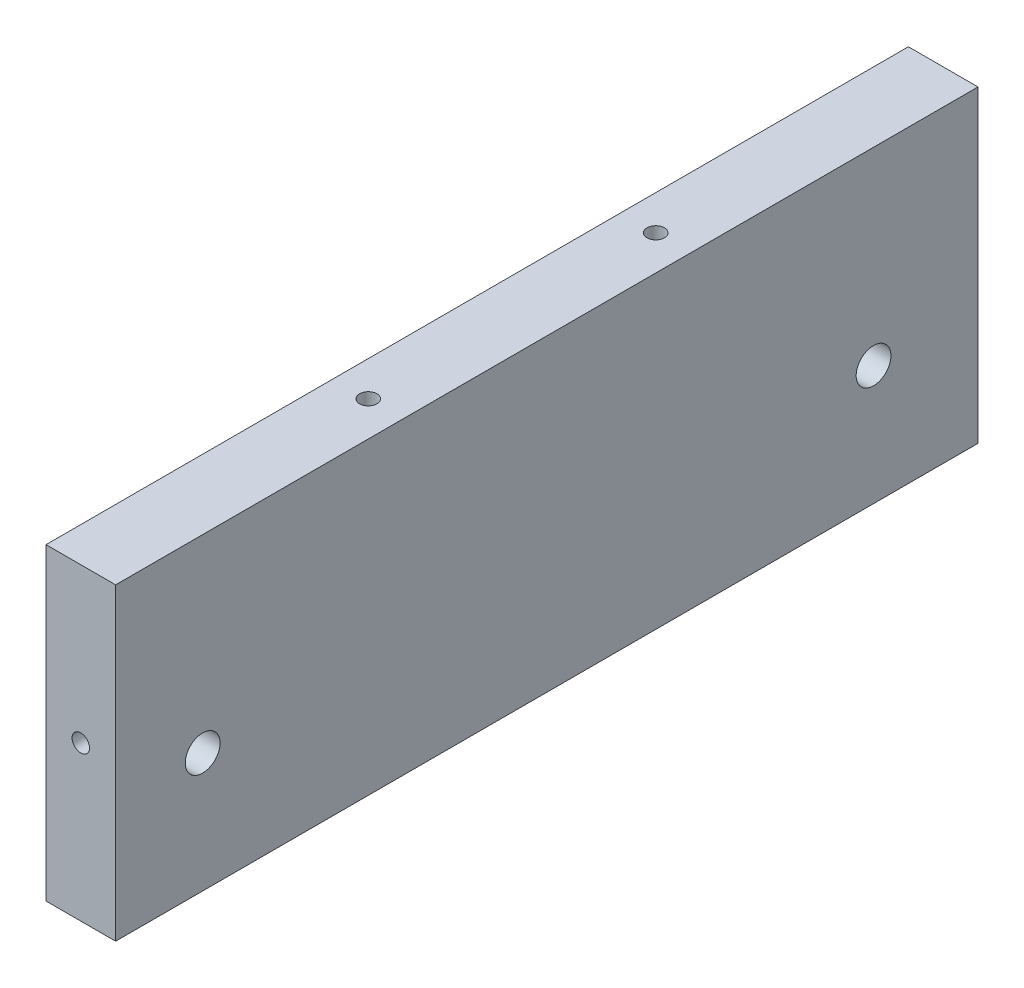
from build123d import *

# Parameters (mm, degrees)
SKETCH1_W                   = 12.7
SKETCH1_H                   = 56.3
BOSS_EXTRUDE1_DEPTH         = 157.3
HOLE1_D                     = 3.175
HOLE1_DEPTH                 = 31.75
HOLE1_CSINK_D               = 10.16
HOLE1_CSINK_ANGLE           = 82
HOLE1_TIP                   = 0.953866233
HOLE2_D                     = 3.175
HOLE2_DEPTH                 = 31.75
HOLE2_CSINK_D               = 10.16
HOLE2_CSINK_ANGLE           = 82
HOLE2_TIP                   = 0.953866233
HOLE_D                      = 3.175
HOLE_DEPTH                  = 31.75
HOLE_CSINK_D                = 10.16
HOLE_CSINK_ANGLE            = 82
HOLE_TIP                    = 0.953866233
HOLE3_D                     = 3.175
HOLE3_DEPTH                 = 31.75
HOLE3_CSINK_D               = 10.16
HOLE3_CSINK_ANGLE           = 82
HOLE3_TIP                   = 0.953866233
HOLE4_D                     = 3.175
HOLE4_DEPTH                 = 31.75
HOLE4_CSINK_D               = 10.16
HOLE4_CSINK_ANGLE           = 82
HOLE4_TIP                   = 0.953866233
F_1_4_0_25_DIAMETER_HOLE1_D = 6.35


with BuildPart() as part:
    # Sketch1 → Boss-Extrude1 (new body)
    with BuildSketch(Plane.XY):
        with Locations((-237.654465963, 40.85)):
            Rectangle(SKETCH1_W, SKETCH1_H)
    extrude(amount=BOSS_EXTRUDE1_DEPTH)

    # Hole1
    with Locations(Plane(origin=(-124.004465969, 0, 2.275709941), x_dir=(1, 0, 0), z_dir=(0, -1, 0))):
        with Locations((113.649999994, 128.807623392), (113.649999994, 23.940956725), (-94.599999994, 161.374290059), (94.599999994, 161.374290059), (0, 161.374290059), (0, 193.124290059), (0, 440.553783621), (0, 301.970350905), (40.979166666, 301.970350905), (166.795833328, 301.970350905), (207.774999994, 440.553783621), (207.774999994, 333.02141023), (207.774999994, 225.48903684), (207.774999994, 137.424290059), (207.774999994, 10.424290059), (-207.774999994, 10.424290059), (-207.774999994, 137.424290059), (-207.774999994, 225.48903684), (-207.774999994, 333.02141023), (-207.774999994, 440.553783621), (-166.795833328, 301.970350905), (-40.979166666, 301.970350905), (-113.649999994, 23.940956725), (-113.649999994, 128.807623392)):
            CounterSinkHole(HOLE1_D / 2, HOLE1_CSINK_D / 2, depth=HOLE1_DEPTH, counter_sink_angle=HOLE1_CSINK_ANGLE)
            with Locations((0, 0, -(HOLE1_DEPTH + HOLE1_TIP / 2))):  # 118° drill point
                Cone(0, HOLE1_D / 2, HOLE1_TIP, mode=Mode.SUBTRACT)

    # Hole2
    with Locations(Plane(origin=(-124.004465969, 0, 155.024290059), x_dir=(-1, 0, 0), z_dir=(0, -1, 0))):
        with Locations((113.649999994, 128.807623392), (113.649999994, 23.940956725), (-94.599999994, 161.374290059), (94.599999994, 161.374290059), (0, 161.374290059), (0, 193.124290059), (0, 440.553783621), (0, 301.970350905), (40.979166666, 301.970350905), (166.795833328, 301.970350905), (207.774999994, 440.553783621), (207.774999994, 333.02141023), (207.774999994, 225.48903684), (207.774999994, 137.424290059), (207.774999994, 10.424290059), (-207.774999994, 10.424290059), (-207.774999994, 137.424290059), (-207.774999994, 225.48903684), (-207.774999994, 333.02141023), (-207.774999994, 440.553783621), (-166.795833328, 301.970350905), (-40.979166666, 301.970350905), (-113.649999994, 23.940956725), (-113.649999994, 128.807623392)):
            CounterSinkHole(HOLE2_D / 2, HOLE2_CSINK_D / 2, depth=HOLE2_DEPTH, counter_sink_angle=HOLE2_CSINK_ANGLE)
            with Locations((0, 0, -(HOLE2_DEPTH + HOLE2_TIP / 2))):  # 118° drill point
                Cone(0, HOLE2_D / 2, HOLE2_TIP, mode=Mode.SUBTRACT)

    # Hole
    with Locations(Plane(origin=(-124.004465969, 277.286738577, 170), x_dir=(-1, 0, 0), z_dir=(0, 0, 1))):
        with Locations((113.649999994, 236.436738577), (207.774999994, 236.436738577)):
            CounterSinkHole(HOLE_D / 2, HOLE_CSINK_D / 2, depth=HOLE_DEPTH, counter_sink_angle=HOLE_CSINK_ANGLE)
            with Locations((0, 0, -(HOLE_DEPTH + HOLE_TIP / 2))):  # 118° drill point
                Cone(0, HOLE_D / 2, HOLE_TIP, mode=Mode.SUBTRACT)

    # Hole3
    with Locations(Plane(origin=(-124.004465969, 88.05, 155.024290059), x_dir=(1, 0, 0), z_dir=(0, 1, 0))):
        with Locations((-162.299999994, -8.625709941), (-113.649999994, 50.157623392), (-113.649999994, 102.590956725), (162.299999994, -8.625709941), (113.649999994, 50.157623392), (113.649999994, 102.590956725), (63.85, 161.374290059), (0, 161.374290059), (-63.85, 161.374290059)):
            CounterSinkHole(HOLE3_D / 2, HOLE3_CSINK_D / 2, depth=HOLE3_DEPTH, counter_sink_angle=HOLE3_CSINK_ANGLE)
            with Locations((0, 0, -(HOLE3_DEPTH + HOLE3_TIP / 2))):  # 118° drill point
                Cone(0, HOLE3_D / 2, HOLE3_TIP, mode=Mode.SUBTRACT)

    # Hole4
    with Locations(Plane(origin=(-124.004465969, 88.05, 2.275709941), x_dir=(-1, 0, 0), z_dir=(0, 1, 0))):
        with Locations((-162.299999994, -8.625709941), (-113.649999994, 50.157623392), (-113.649999994, 102.590956725), (162.299999994, -8.625709941), (113.649999994, 50.157623392), (113.649999994, 102.590956725), (63.85, 161.374290059), (0, 161.374290059), (-63.85, 161.374290059)):
            CounterSinkHole(HOLE4_D / 2, HOLE4_CSINK_D / 2, depth=HOLE4_DEPTH, counter_sink_angle=HOLE4_CSINK_ANGLE)
            with Locations((0, 0, -(HOLE4_DEPTH + HOLE4_TIP / 2))):  # 118° drill point
                Cone(0, HOLE4_D / 2, HOLE4_TIP, mode=Mode.SUBTRACT)

    # 1/4 (0.25) Diameter Hole1 (through all)
    with Locations(Plane.ZY.offset(244.004465963)):
        with Locations((141.425, 34.5), (19.05, 34.5)):
            Hole(F_1_4_0_25_DIAMETER_HOLE1_D / 2)


solid = part.part
